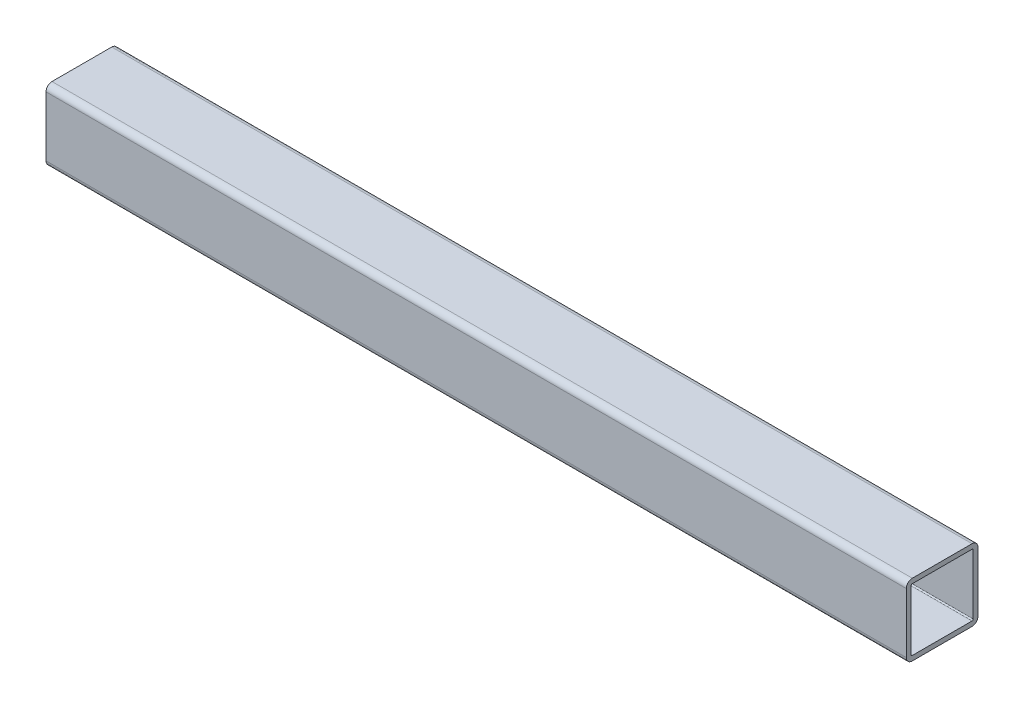
from build123d import *

# Parameters (mm, degrees)
EXTRUDE_THIN1_DEPTH = 228.6


with BuildPart() as part:
    # Sketch1 → Extrude-Thin1 (new body, symmetric)
    with BuildSketch(Plane(origin=(0, 0, 0), x_dir=(0, 0, -1), z_dir=(1, 0, 0))):
        with BuildLine():
            Line((-15.875, 19.05), (15.875, 19.05))
            ThreePointArc((15.875, 19.05), (18.12006403, 18.12006403), (19.05, 15.875))
            Line((19.05, 15.875), (19.05, -15.875))
            ThreePointArc((19.05, -15.875), (18.12006403, -18.12006403), (15.875, -19.05))
            Line((15.875, -19.05), (-15.875, -19.05))
            ThreePointArc((-15.875, -19.05), (-18.12006403, -18.12006403), (-19.05, -15.875))
            Line((-19.05, -15.875), (-19.05, 15.875))
            ThreePointArc((-19.05, 15.875), (-18.12006403, 18.12006403), (-15.875, 19.05))
        make_face()
        with BuildLine():
            Line((-15.875, 16.51), (15.875, 16.51))
            ThreePointArc((15.875, 16.51), (16.324012806, 16.324012806), (16.51, 15.875))
            Line((16.51, 15.875), (16.51, -15.875))
            ThreePointArc((16.51, -15.875), (16.324012806, -16.324012806), (15.875, -16.51))
            Line((15.875, -16.51), (-15.875, -16.51))
            ThreePointArc((-15.875, -16.51), (-16.324012806, -16.324012806), (-16.51, -15.875))
            Line((-16.51, -15.875), (-16.51, 15.875))
            ThreePointArc((-16.51, 15.875), (-16.324012806, 16.324012806), (-15.875, 16.51))
        make_face(mode=Mode.SUBTRACT)
    extrude(amount=EXTRUDE_THIN1_DEPTH, both=True)


solid = part.part
